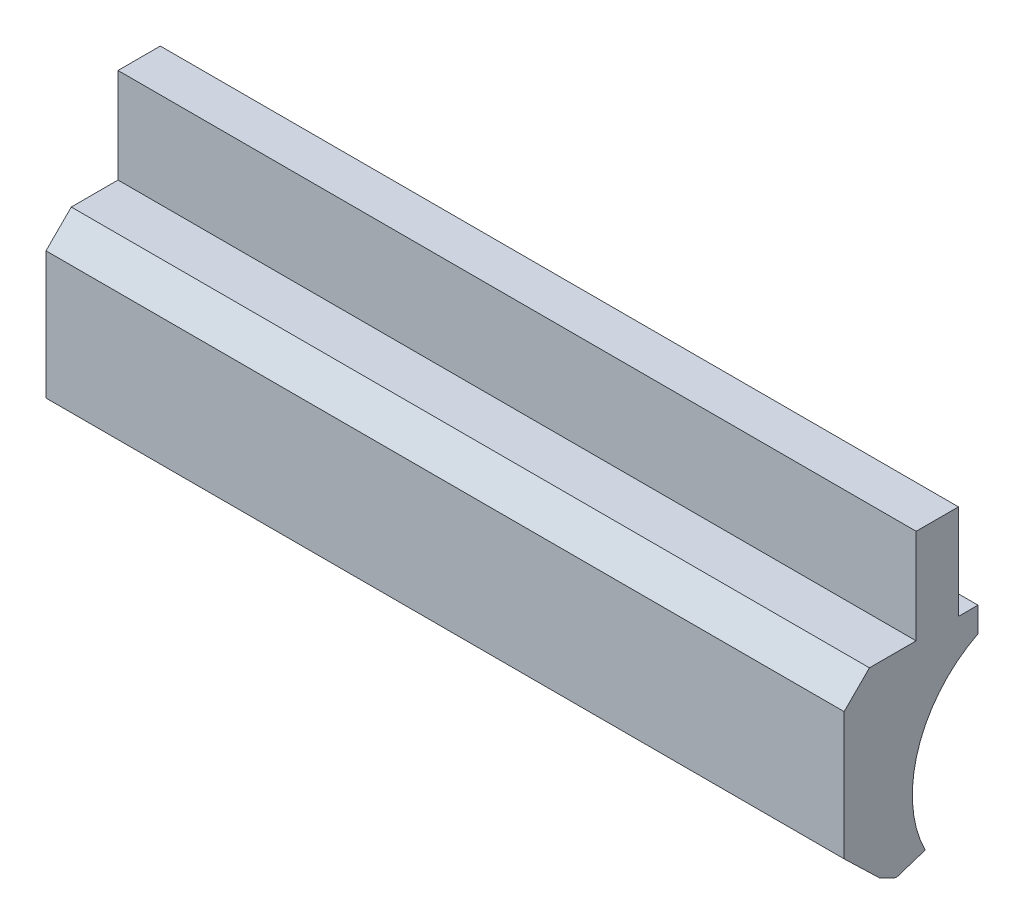
from build123d import *

# Parameters (mm, degrees)
BOSS_EXTRUDE2_DEPTH = 10


with BuildPart() as part:
    # Sketch1 → Boss-Extrude2 (new body)
    with BuildSketch(Plane(origin=(0, 0, 0), x_dir=(0, 0, -1), z_dir=(1, 0, 0))):
        with BuildLine():
            Line((0.181484262, 0.201549296), (-0.348515738, 0.201549296))
            Line((-0.348515738, 0.201549296), (-0.348515738, -0.987434189))
            Line((-0.348515738, -0.987434189), (-0.933817853, -0.987434189))
            Line((-0.933817853, -0.987434189), (-1.25063724, -1.304253576))
            Line((-1.25063724, -1.304253576), (-1.25063724, -2.902375908))
            Line((-1.25063724, -2.902375908), (-0.806436057, -3.331336004))
            Line((-0.806436057, -3.331336004), (-0.598754104, -3.432629261))
            Line((-0.598754104, -3.432629261), (-0.234865404, -3.314394655))
            ThreePointArc((-0.234865404, -3.314394655), (-0.321657185, -2.169629757), (0.42644278, -1.298787678))
            Line((0.42644278, -1.298787678), (0.42644278, -0.987434189))
            Line((0.42644278, -0.987434189), (0.181484262, -0.987434189))
            Line((0.181484262, -0.987434189), (0.181484262, 0.201549296))
        make_face()
    extrude(amount=BOSS_EXTRUDE2_DEPTH)


solid = part.part
